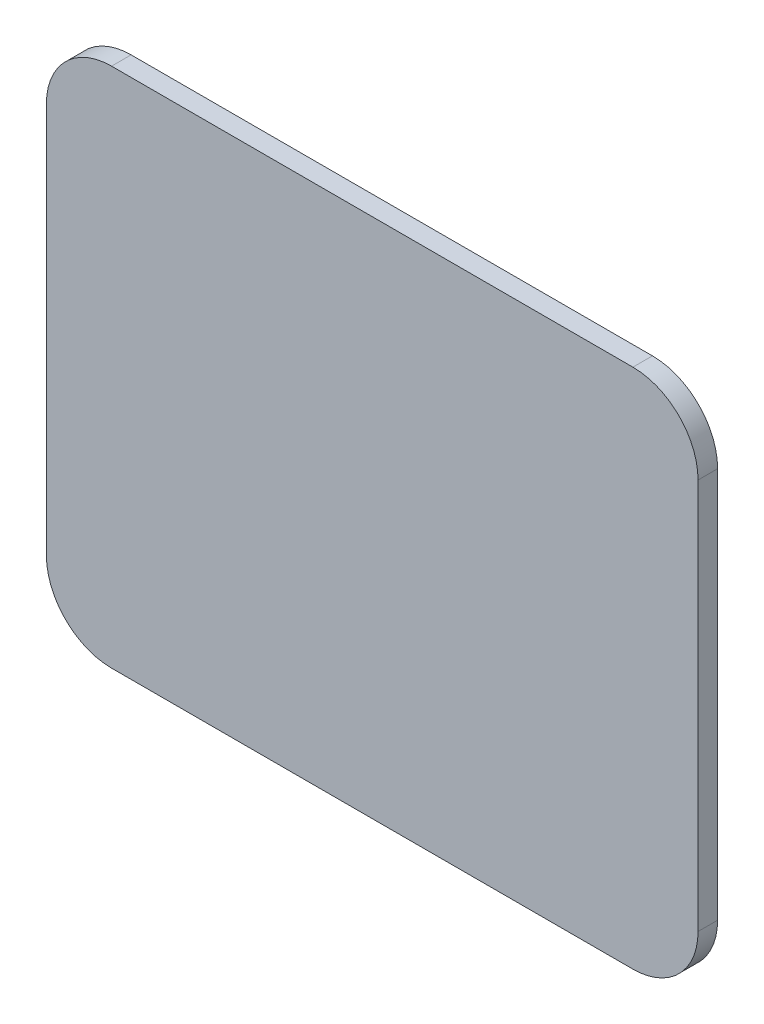
from build123d import *

# Parameters (mm, degrees)
DODANIE_WYCI_GNI_CIE1_DEPTH = 3


with BuildPart() as part:
    # Szkic1 → Dodanie-wyciągnięcie1 (new body)
    with BuildSketch(Plane.XY):
        with BuildLine():
            Line((10, 0), (90, 0))
            ThreePointArc((90, 0), (97.071067812, 2.928932188), (100, 10))
            Line((100, 10), (100, 70))
            ThreePointArc((100, 70), (97.071067812, 77.071067812), (90, 80))
            Line((90, 80), (10, 80))
            ThreePointArc((10, 80), (2.928932188, 77.071067812), (0, 70))
            Line((0, 70), (0, 10))
            ThreePointArc((0, 10), (2.928932188, 2.928932188), (10, 0))
        make_face()
    extrude(amount=DODANIE_WYCI_GNI_CIE1_DEPTH)


solid = part.part
